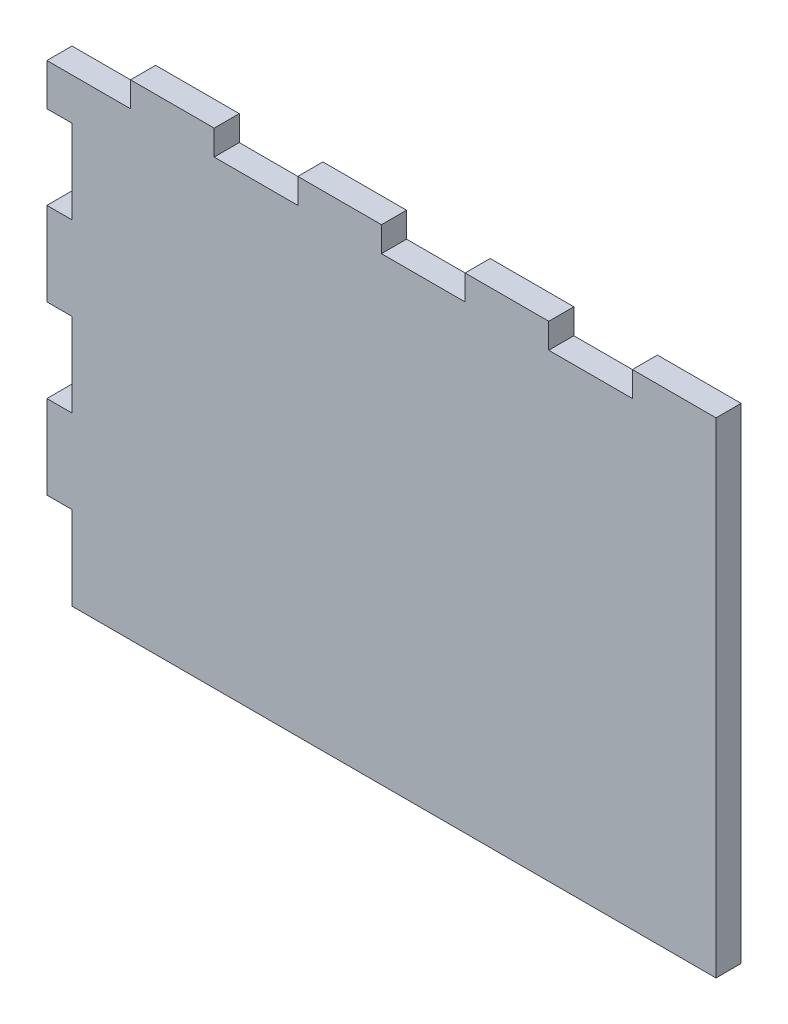
from build123d import *

# Parameters (mm, degrees)
ESQUISSE1_W                = 80
ESQUISSE1_H                = 58
BOSS_EXTRU_1_DEPTH         = 3
ESQUISSE2_W                = 10
ESQUISSE2_H                = 3
ENL_V_MAT_EXTRU_1_DEPTH    = 4
R_P_TITION_LIN_AIRE1_COUNT = 4
R_P_TITION_LIN_AIRE1_PITCH = 20
ESQUISSE3_W                = 3
ESQUISSE3_H                = 10
ENL_V_MAT_EXTRU_2_DEPTH    = 4
R_P_TITION_LIN_AIRE2_COUNT = 3
R_P_TITION_LIN_AIRE2_PITCH = 20


with BuildPart() as part:
    # Esquisse1 → Boss.-Extru.1 (new body)
    with BuildSketch(Plane.XY):
        with Locations((40, -29)):
            Rectangle(ESQUISSE1_W, ESQUISSE1_H)
    extrude(amount=BOSS_EXTRU_1_DEPTH)

    # Esquisse2 → Enlèv. mat.-Extru.1 (cut, through all)
    with BuildSketch(Plane.XY.offset(3)):
        with Locations((5, -1.5)):
            Rectangle(ESQUISSE2_W, ESQUISSE2_H)
    enl_v_mat_extru_1 = extrude(amount=-ENL_V_MAT_EXTRU_1_DEPTH, mode=Mode.SUBTRACT)

    # Répétition linéaire1: Enlèv. mat.-Extru.1 ×4
    with Locations(*[(i * R_P_TITION_LIN_AIRE1_PITCH, 0, 0) for i in range(1, R_P_TITION_LIN_AIRE1_COUNT)]):
        add(enl_v_mat_extru_1, mode=Mode.SUBTRACT)

    # Esquisse3 → Enlèv. mat.-Extru.2 (cut, through all)
    with BuildSketch(Plane.XY.offset(3)):
        with Locations((1.5, -53)):
            Rectangle(ESQUISSE3_W, ESQUISSE3_H)
    enl_v_mat_extru_2 = extrude(amount=-ENL_V_MAT_EXTRU_2_DEPTH, mode=Mode.SUBTRACT)

    # Répétition linéaire2: Enlèv. mat.-Extru.2 ×3
    with Locations(*[(0, i * R_P_TITION_LIN_AIRE2_PITCH, 0) for i in range(1, R_P_TITION_LIN_AIRE2_COUNT)]):
        add(enl_v_mat_extru_2, mode=Mode.SUBTRACT)


solid = part.part
